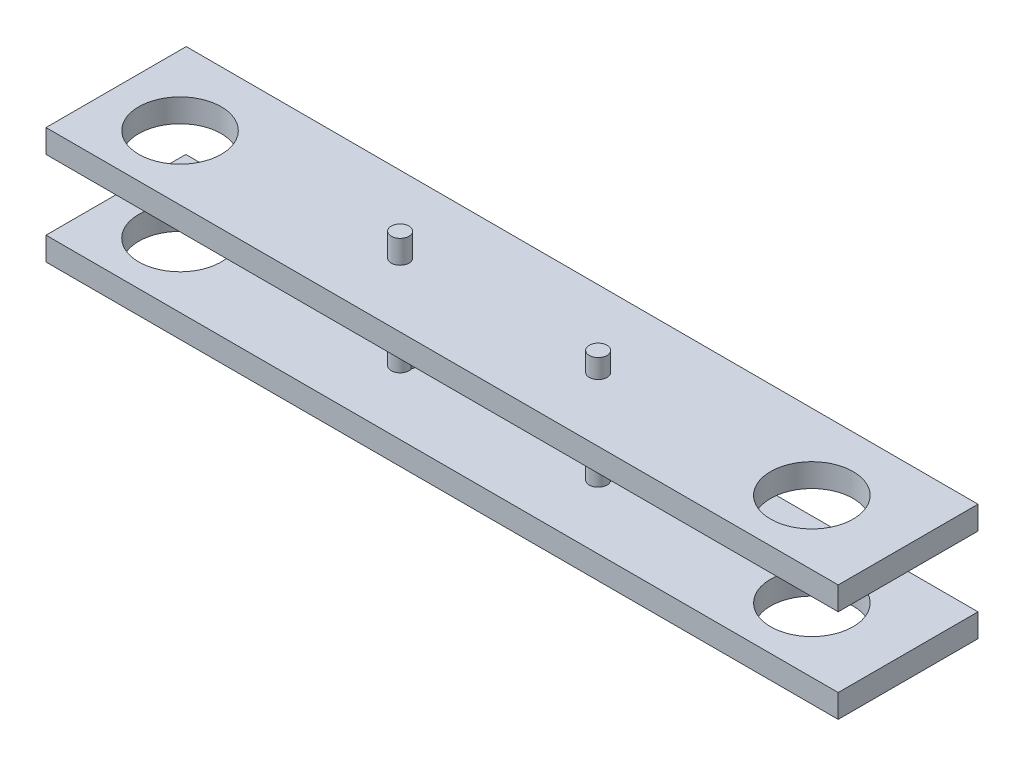
from build123d import *

# Parameters (mm, degrees)
CROQUIS1_W                   = 431.8
CROQUIS1_H                   = 76.2
SALIENTE_EXTRUIR2_DEPTH      = 12.7
CROQUIS3_R                   = 4.826
SALIENTE_EXTRUIR4_DEPTH      = 63.5
CROQUIS4_R                   = 22.479
CORTAR_EXTRUIR3_DEPTH        = 219.71
CROQUIS6_R                   = 22.479
CORTAR_EXTRUIR5_DEPTH        = 180.594
SALIENTE_EXTRUIR5_DEPTH      = 12.7
CROQUIS8_R                   = 22.479
CORTAR_EXTRUIR7_DEPTH        = 46.736
CORTAR_EXTRUIR7_DEPTH_BACK   = 115.062
CROQUIS9_R                   = 22.479
CORTAR_EXTRUIR8_DEPTH        = 153.162
CORTAR_EXTRUIR8_DEPTH_BACK   = 103.886
CROQUIS10_R                  = 4.826
SALIENTE_EXTRUIR6_DEPTH      = 10.414
SALIENTE_EXTRUIR6_DEPTH_BACK = 75.184
CROQUIS12_R                  = 4.826
SALIENTE_EXTRUIR7_DEPTH      = 76.2
SALIENTE_EXTRUIR7_DEPTH_BACK = 13.208


with BuildPart() as part:
    # Croquis1 → Saliente-Extruir2 (new body)
    with BuildSketch(Plane(origin=(0, 0, 0), x_dir=(1, 0, 0), z_dir=(0, 1, 0))):
        with Locations((108.703948782, 38.1)):
            Rectangle(CROQUIS1_W, CROQUIS1_H)
    extrude(amount=SALIENTE_EXTRUIR2_DEPTH)

    # Croquis3 → Saliente-Extruir4 (add)
    with BuildSketch(Plane(origin=(0, 0, 0), x_dir=(1, 0, 0), z_dir=(0, 1, 0))):
        with Locations((-53.918932068, 38.1)):
            Circle(CROQUIS3_R)
        with Locations((51.017757536, 38.1)):
            Circle(CROQUIS3_R)
    extrude(amount=SALIENTE_EXTRUIR4_DEPTH)

    # Croquis4 → Cortar-Extruir3 (cut)
    with BuildSketch(Plane(origin=(0, 0, 0), x_dir=(1, 0, 0), z_dir=(0, 1, 0))):
        with Locations((275.131003884, 35.107884956)):
            Circle(CROQUIS4_R)
    extrude(amount=CORTAR_EXTRUIR3_DEPTH, mode=Mode.SUBTRACT)

    # Croquis6 → Cortar-Extruir5 (cut)
    with BuildSketch(Plane(origin=(0, 0, 0), x_dir=(1, 0, 0), z_dir=(0, 1, 0))):
        with Locations((275.131003884, 35.107884956)):
            Circle(CROQUIS6_R)
    extrude(amount=CORTAR_EXTRUIR5_DEPTH, mode=Mode.SUBTRACT)

    # Croquis7 → Saliente-Extruir5 (add)
    with BuildSketch(Plane(origin=(0, 50.8, 0), x_dir=(1, 0, 0), z_dir=(0, 1, 0))):
        Polygon((-107.196051218, 0), (-107.196051218, 76.439679068), (324.603948782, 76.2), (324.603948782, 0), align=None)
    extrude(amount=SALIENTE_EXTRUIR5_DEPTH)

    # Croquis8 → Cortar-Extruir7 (cut, two sides)
    with BuildSketch(Plane.XZ) as cortar_extruir7_sk:
        with Locations((275.131003884, -35.107884956)):
            Circle(CROQUIS8_R)
    extrude(amount=CORTAR_EXTRUIR7_DEPTH, mode=Mode.SUBTRACT)
    extrude(cortar_extruir7_sk.sketch, amount=-CORTAR_EXTRUIR7_DEPTH_BACK, mode=Mode.SUBTRACT)

    # Croquis9 → Cortar-Extruir8 (cut, two sides)
    with BuildSketch(Plane(origin=(0, 0, 0), x_dir=(1, 0, 0), z_dir=(0, 1, 0))) as cortar_extruir8_sk:
        with Locations((-69.256061559, 35.107884956)):
            Circle(CROQUIS9_R)
    extrude(amount=CORTAR_EXTRUIR8_DEPTH, mode=Mode.SUBTRACT)
    extrude(cortar_extruir8_sk.sketch, amount=-CORTAR_EXTRUIR8_DEPTH_BACK, mode=Mode.SUBTRACT)

    # Croquis10 → Saliente-Extruir6 (add, two sides)
    with BuildSketch(Plane(origin=(0, 63.5, 0), x_dir=(1, 0, 0), z_dir=(0, 1, 0))) as saliente_extruir6_sk:
        with Locations((158.865028896, 34.905026744)):
            Circle(CROQUIS10_R)
    extrude(amount=SALIENTE_EXTRUIR6_DEPTH)
    extrude(saliente_extruir6_sk.sketch, amount=-SALIENTE_EXTRUIR6_DEPTH_BACK)

    # Croquis12 → Saliente-Extruir7 (add, two sides)
    with BuildSketch(Plane(origin=(0, 0, 0), x_dir=(1, 0, 0), z_dir=(0, 1, 0))) as saliente_extruir7_sk:
        with Locations((50.915028896, 34.905026744)):
            Circle(CROQUIS12_R)
    extrude(amount=SALIENTE_EXTRUIR7_DEPTH)
    extrude(saliente_extruir7_sk.sketch, amount=-SALIENTE_EXTRUIR7_DEPTH_BACK)


solid = part.part
